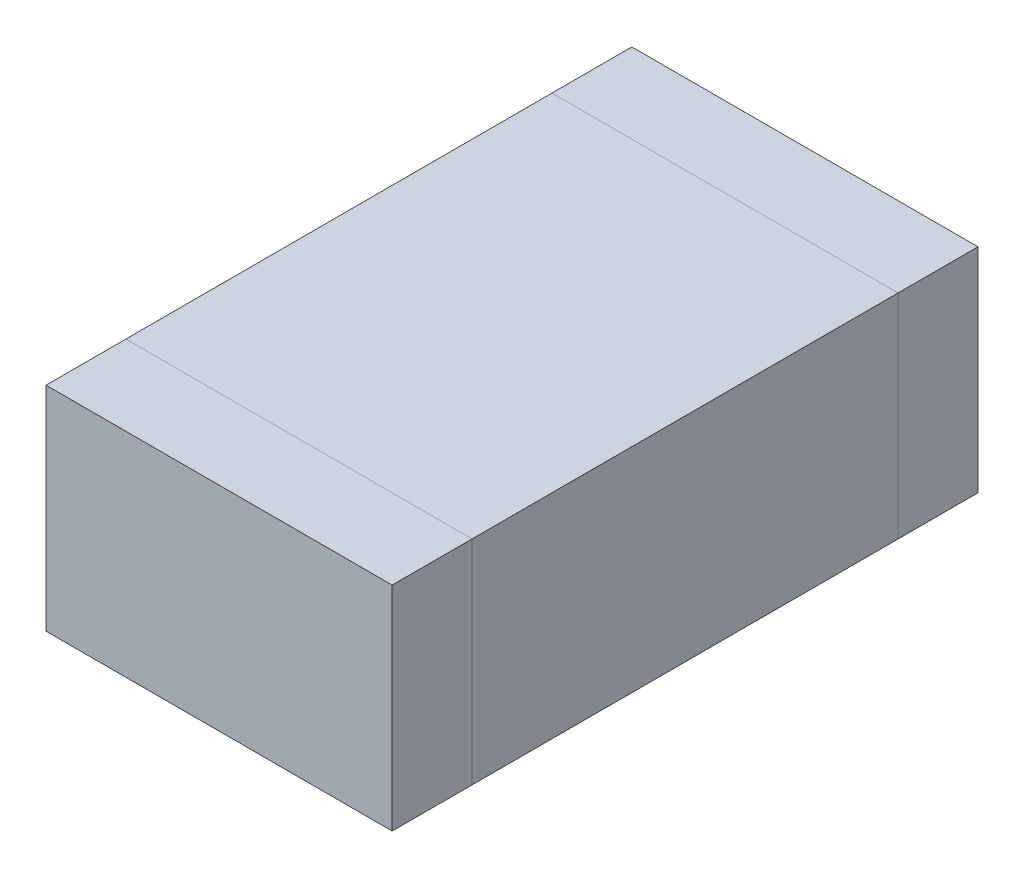
from build123d import *

# Parameters (mm, degrees)
SKETCH1_W  = 1.3
SKETCH1_H  = 1.6
MB_DEPTH   = 0.8
SKETCH2_W  = 1.3
SKETCH2_H  = 0.8
SB_L_DEPTH = 0.3
SKETCH3_W  = 1.3
SKETCH3_H  = 0.8
SB_R_DEPTH = 0.3


with BuildPart() as part:
    # Sketch1 → MB (new body)
    with BuildSketch(Plane(origin=(0, 0, 0), x_dir=(1, 0, 0), z_dir=(0, 1, 0))):
        Rectangle(SKETCH1_W, SKETCH1_H)
    extrude(amount=MB_DEPTH)


with BuildPart() as body_2:
    # Sketch2 → SB L (new body)
    with BuildSketch(Plane.XY.offset(0.8)):
        with Locations((0, 0.4)):
            Rectangle(SKETCH2_W, SKETCH2_H)
    extrude(amount=SB_L_DEPTH)


with BuildPart() as body_3:
    # Sketch3 → SB R (new body)
    with BuildSketch(Plane(origin=(0, 0, -0.8), x_dir=(-1, 0, 0), z_dir=(0, 0, -1))):
        with Locations((0, 0.4)):
            Rectangle(SKETCH3_W, SKETCH3_H)
    extrude(amount=SB_R_DEPTH)


solid = Compound([part.part, body_2.part, body_3.part])
